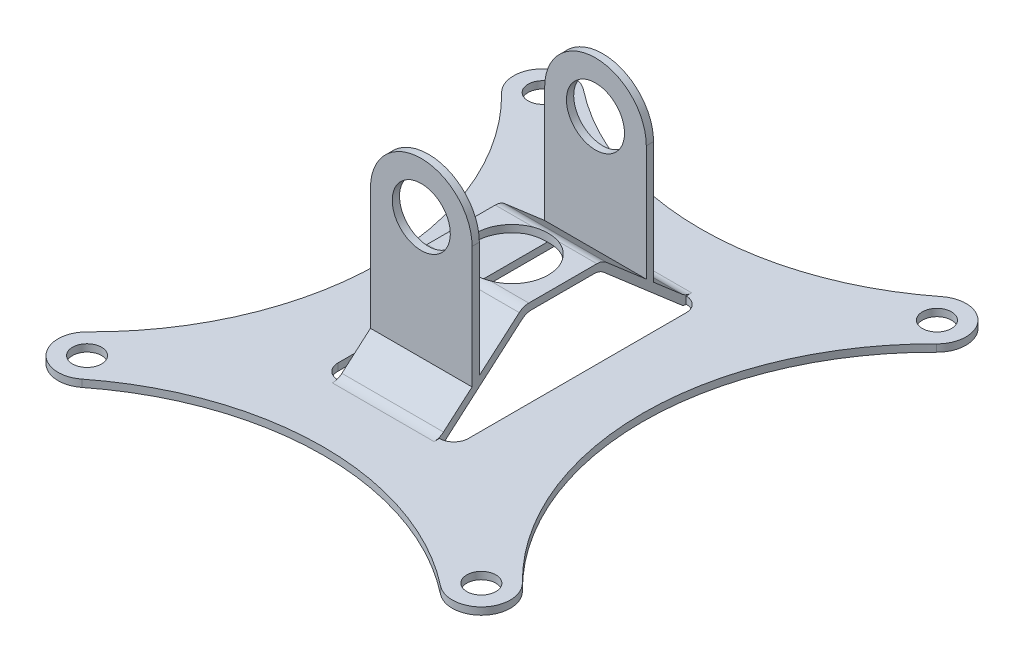
from build123d import *

# Parameters (mm, degrees)
BOSS_EXTRUDE1_DEPTH = 3.175
BOSS_EXTRUDE3_DEPTH = 22.225
SKETCH5_R           = 15.875
CUT_EXTRUDE1_DEPTH  = 35.925
SKETCH6_R           = 12.7
CUT_EXTRUDE2_DEPTH  = 79.375
FILLET1_R           = 6.35
SKETCH1_5_R         = 6.35
HOLES_DEPTH         = 92.0082


with BuildPart() as part:
    # Sketch1 → Boss-Extrude1 (new body)
    with BuildSketch(Plane(origin=(0, 0, 0), x_dir=(1, 0, 0), z_dir=(0, 1, 0))):
        with BuildLine():
            ThreePointArc((-78.393636364, 109.635915457), (-95.772926059, 108.027505481), (-95.134259734, 90.585636364))
            ThreePointArc((-95.134259734, 90.585636364), (-57.14685707, 0), (-95.134259734, -90.585636364))
            ThreePointArc((-95.134259734, -90.585636364), (-95.772926059, -108.027505481), (-78.393636364, -109.635915457))
            ThreePointArc((-78.393636364, -109.635915457), (0, -82.553070029), (78.393636364, -109.635915457))
            ThreePointArc((78.393636364, -109.635915457), (95.772926059, -108.027505481), (95.134259734, -90.585636364))
            ThreePointArc((95.134259734, -90.585636364), (57.14685707, 0), (95.134259734, 90.585636364))
            ThreePointArc((95.134259734, 90.585636364), (95.772926059, 108.027505481), (78.393636364, 109.635915457))
            ThreePointArc((78.393636364, 109.635915457), (0, 82.553070029), (-78.393636364, 109.635915457))
        make_face()
        with BuildLine():
            Line((-22.225, -53.975), (22.225, -53.975))
            ThreePointArc((22.225, -53.975), (26.715128061, -52.115128061), (28.575, -47.625))
            Line((28.575, -47.625), (28.575, 47.625))
            ThreePointArc((28.575, 47.625), (26.715128061, 52.115128061), (22.225, 53.975))
            Line((22.225, 53.975), (-22.225, 53.975))
            ThreePointArc((-22.225, 53.975), (-26.715128061, 52.115128061), (-28.575, 47.625))
            Line((-28.575, 47.625), (-28.575, -47.625))
            ThreePointArc((-28.575, -47.625), (-26.715128061, -52.115128061), (-22.225, -53.975))
        make_face(mode=Mode.SUBTRACT)
    extrude(amount=BOSS_EXTRUDE1_DEPTH)

    # Sketch4 → Boss-Extrude3 (add, symmetric)
    with BuildSketch(Plane(origin=(0, 0, 0), x_dir=(0, 0, -1), z_dir=(1, 0, 0))):
        with BuildLine():
            ThreePointArc((53.975, 0), (52.866902818, 0.199643612), (51.898159667, 0.773467316))
            Line((51.898159667, 0.773467316), (17.867550541, 30.203065368))
            ThreePointArc((17.867550541, 30.203065368), (15.930064238, 31.350712776), (13.713869875, 31.75))
            Line((13.713869875, 31.75), (-13.713869875, 31.75))
            ThreePointArc((-13.713869875, 31.75), (-15.930064238, 31.350712776), (-17.867550541, 30.203065368))
            Line((-17.867550541, 30.203065368), (-51.898159667, 0.773467316))
            ThreePointArc((-51.898159667, 0.773467316), (-52.866902818, 0.199643612), (-53.975, 0))
            Line((-53.975, 0), (-53.975, 3.175))
            Line((-53.975, 3.175), (-19.05, 33.378065368))
            ThreePointArc((-19.05, 33.378065368), (-17.112513698, 34.525712776), (-14.896319334, 34.925))
            Line((-14.896319334, 34.925), (14.896319334, 34.925))
            ThreePointArc((14.896319334, 34.925), (17.112513698, 34.525712776), (19.05, 33.378065368))
            Line((19.05, 33.378065368), (53.975, 3.175))
            Line((53.975, 3.175), (53.975, 0))
        make_face()
        Polygon((-39.6875, 91.0082), (-39.6875, 15.530799469), (-36.5125, 18.276532684), (-36.5125, 91.0082), align=None)
        Polygon((36.5125, 91.0082), (36.5125, 18.276532684), (39.6875, 15.530799469), (39.6875, 91.0082), align=None)
    extrude(amount=BOSS_EXTRUDE3_DEPTH, both=True)

    # Sketch5 → Cut-Extrude1 (cut, through all)
    with BuildSketch(Plane(origin=(0, 34.925, 0), x_dir=(1, 0, 0), z_dir=(0, 1, 0))):
        Circle(SKETCH5_R)
    extrude(amount=-CUT_EXTRUDE1_DEPTH, mode=Mode.SUBTRACT)

    # Sketch6 → Cut-Extrude2 (cut)
    with BuildSketch(Plane(origin=(0, 0, -39.6875), x_dir=(-1, 0, 0), z_dir=(0, 0, -1))):
        with Locations((0, 68.7832)):
            Circle(SKETCH6_R)
        with BuildLine():
            ThreePointArc((-22.225, 68.7832), (-15.715448152, 84.498648271), (1.69e-07, 91.0082))
            Line((1.69e-07, 91.0082), (-22.225, 91.0082))
            Line((-22.225, 91.0082), (-22.225, 68.7832))
        make_face()
        with BuildLine():
            Line((22.225, 68.7832), (22.225, 91.0082))
            Line((22.225, 91.0082), (1.69e-07, 91.0082))
            ThreePointArc((1.69e-07, 91.0082), (15.715448271, 84.498648152), (22.225, 68.7832))
        make_face()
    extrude(amount=-CUT_EXTRUDE2_DEPTH, mode=Mode.SUBTRACT)

    # Fillet1
    fillet1_edges = [part.edges().sort_by_distance(p)[0] for p in [
        (0, 3.175, -53.975),
        (0, 3.175, 53.975),
    ]]
    fillet(fillet1_edges, radius=FILLET1_R)

    # Sketch1_5 → holes (cut, through all)
    with BuildSketch(Plane(origin=(0, 0, 0), x_dir=(1, 0, 0), z_dir=(0, 1, 0))):
        with Locations((-86.233, 99.6442)):
            Circle(SKETCH1_5_R)
        with Locations((86.233, 99.6442)):
            Circle(SKETCH1_5_R)
        with Locations((86.233, -99.6442)):
            Circle(SKETCH1_5_R)
        with Locations((-86.233, -99.6442)):
            Circle(SKETCH1_5_R)
    extrude(amount=HOLES_DEPTH, mode=Mode.SUBTRACT)


solid = part.part
